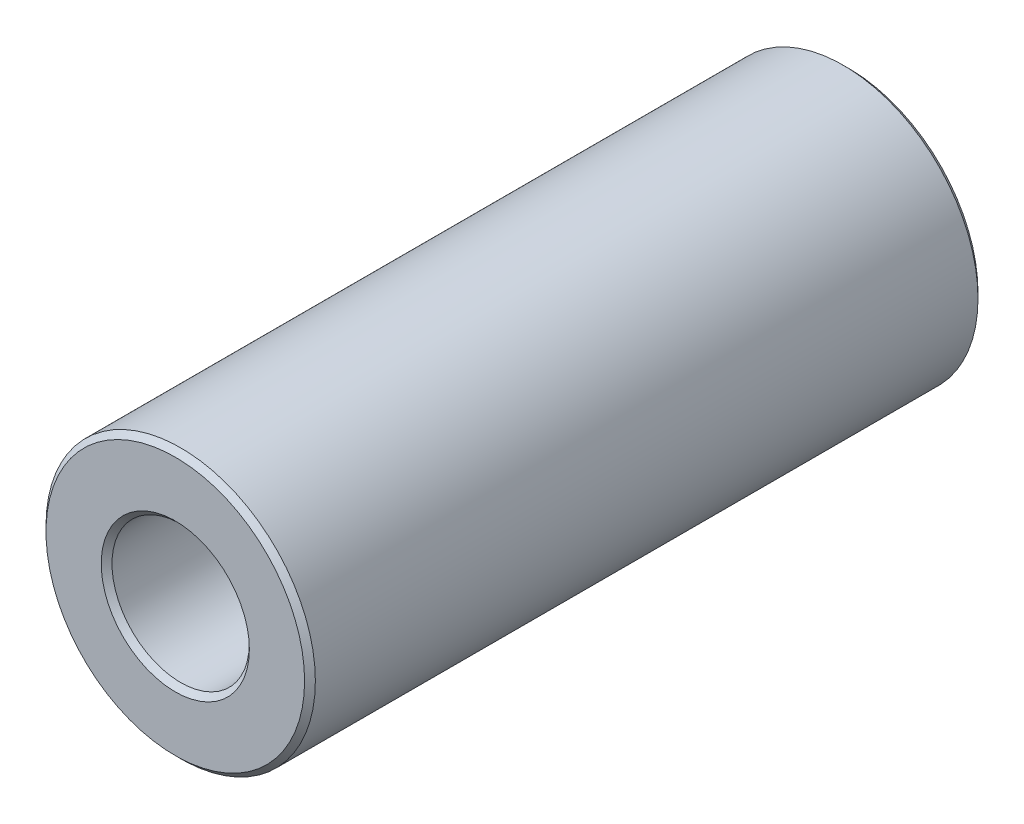
from build123d import *

# Parameters (mm, degrees)
SKETCH1_R           = 5
SKETCH1_R_2         = 2.55
BOSS_EXTRUDE1_DEPTH = 25
CHAMFER1_SIZE       = 0.2


with BuildPart() as part:
    # Sketch1 → Boss-Extrude1 (new body)
    with BuildSketch(Plane.XY):
        Circle(SKETCH1_R)
        Circle(SKETCH1_R_2, mode=Mode.SUBTRACT)
    extrude(amount=BOSS_EXTRUDE1_DEPTH)

    # Chamfer1
    chamfer1_edges = [part.edges().sort_by_distance(p)[0] for p in [
        (-5, 0, 0),
        (-5, 0, 25),
        (-2.55, 0, 0),
        (-2.55, 0, 25),
    ]]
    chamfer(chamfer1_edges, length=CHAMFER1_SIZE)


solid = part.part
